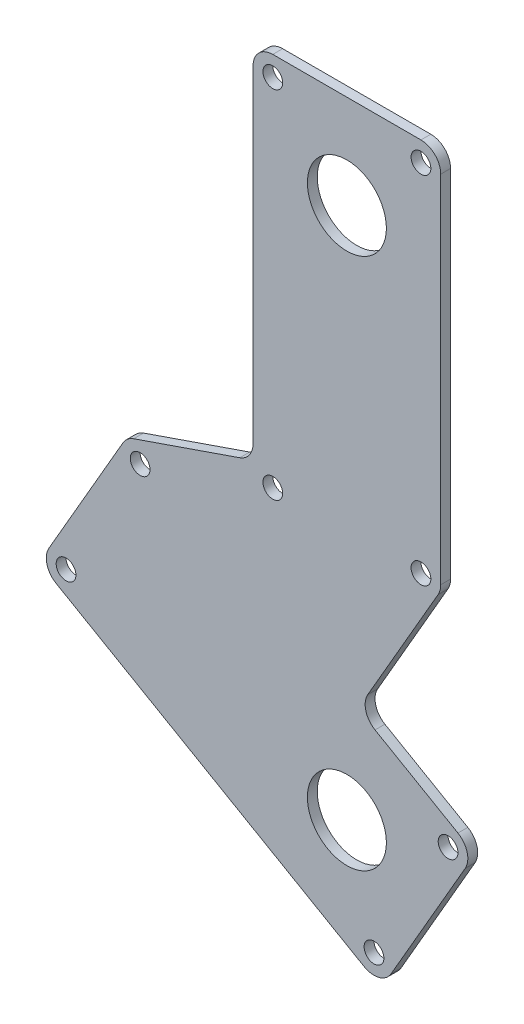
from build123d import *

# Parameters (mm, degrees)
SKETCH1_R           = 1
BOSS_EXTRUDE1_DEPTH = 1
FILLET1_R           = 2


with BuildPart() as part:
    # Sketch1 → Boss-Extrude1 (new body)
    with BuildSketch(Plane.XY):
        Polygon((-9.5, 20), (-9.5, -16.574119451), (-22.29015667, -20.984816263), (-31.163774815, -36.354373739), (3.477241336, -56.354373739), (12.977241336, -39.899891067), (1.11843014, -33.05320323), (9.5, -18.535898385), (9.5, 20), align=None)
        with Locations((-28.431724008, -35.622322931)):
            Circle(SKETCH1_R, mode=Mode.SUBTRACT)
        with BuildLine():
            ThreePointArc((-20.065698604, -23.131941874), (-21.897649834, -22.373122829), (-19.931724008, -22.631941874))
            ThreePointArc((-19.931724008, -22.631941874), (-19.965798182, -22.890760919), (-20.065698604, -23.131941874))
        make_face(mode=Mode.SUBTRACT)
        with BuildLine():
            ThreePointArc((4, -43.377132403), (-2.828427125, -46.205559527), (0, -39.377132403))
            ThreePointArc((0, -39.377132403), (2.828427125, -40.548705278), (4, -43.377132403))
        make_face(mode=Mode.SUBTRACT)
        with Locations((2.745190528, -53.622322931)):
            Circle(SKETCH1_R, mode=Mode.SUBTRACT)
        with Locations((10.245190528, -40.631941874)):
            Circle(SKETCH1_R, mode=Mode.SUBTRACT)
        with Locations((-7.5, -18)):
            Circle(SKETCH1_R, mode=Mode.SUBTRACT)
        with Locations((7.5, -18)):
            Circle(SKETCH1_R, mode=Mode.SUBTRACT)
        with Locations((-7.5, 18)):
            Circle(SKETCH1_R, mode=Mode.SUBTRACT)
        with BuildLine():
            ThreePointArc((4, 10.5), (2.828427125, 7.671572875), (0, 6.5))
            ThreePointArc((0, 6.5), (-2.828427125, 13.328427125), (4, 10.5))
        make_face(mode=Mode.SUBTRACT)
        with Locations((7.5, 18)):
            Circle(SKETCH1_R, mode=Mode.SUBTRACT)
    extrude(amount=BOSS_EXTRUDE1_DEPTH)

    # Fillet1
    fillet1_edges = [part.edges().sort_by_distance(p)[0] for p in [
        (-9.5, 20, 0.5),
        (9.5, 20, 0.5),
        (9.5, -18.535898385, 0.5),
        (-22.29015667, -20.984816263, 0.5),
        (-31.163774815, -36.354373739, 0.5),
        (3.477241336, -56.354373739, 0.5),
        (12.977241336, -39.899891067, 0.5),
        (1.11843014, -33.05320323, 0.5),
        (-9.5, -16.574119451, 0.5),
    ]]
    fillet(fillet1_edges, radius=FILLET1_R)


solid = part.part
